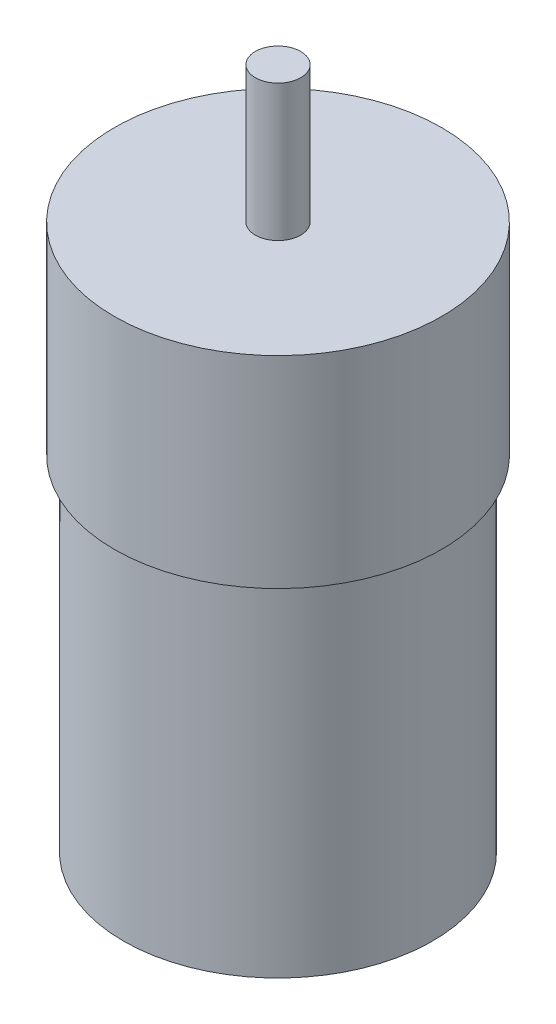
from build123d import *


with BuildPart() as part:
    # Sketch2 → Revolve2 (revolve)
    with BuildSketch(Plane.XY):
        Polygon((0, 0), (0, -60), (17, -60), (17, -22.191780822), (18, -22.191780822), (18, 0), (2.5, 0), (2.5, 15), (0, 15), align=None)
    revolve(axis=Axis((0, 55.382183213, 0), (0, -1, 0)))


solid = part.part
